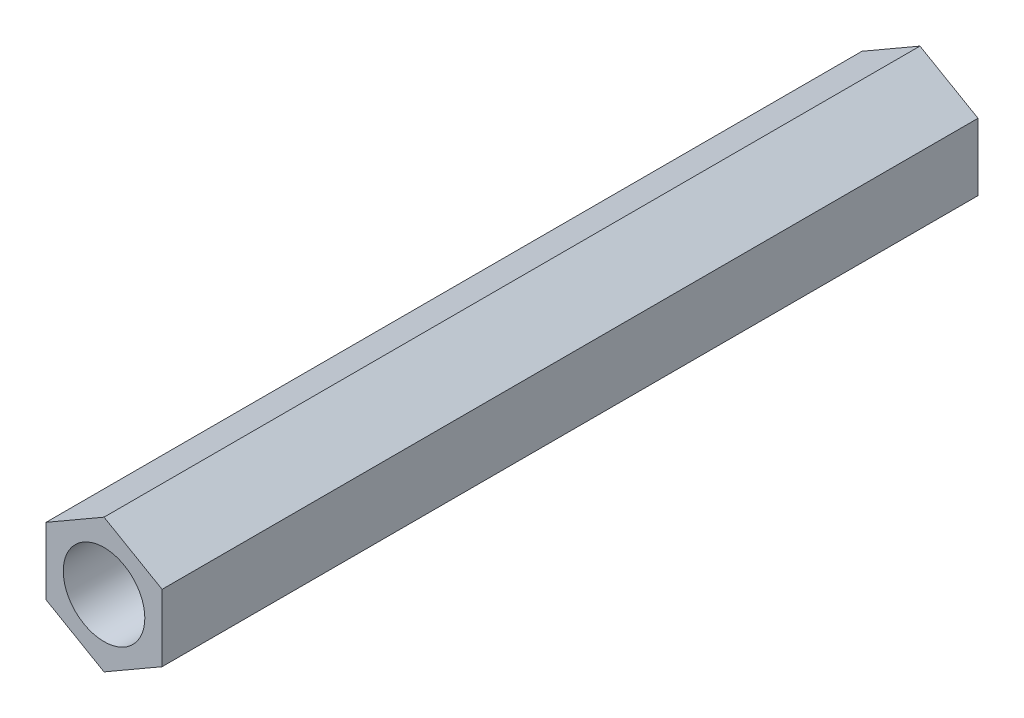
from build123d import *

# Parameters (mm, degrees)
SKETCH_1_R      = 1.5
EXTRUDE_1_DEPTH = 30


with BuildPart() as part:
    # 草图1 → 凸台-拉伸1 (new body)
    with BuildSketch(Plane.XY):
        Polygon((0, 2.463929225), (-2.133825302, 1.231964612), (-2.133825302, -1.231964612), (0, -2.463929225), (2.133825302, -1.231964612), (2.133825302, 1.231964612), align=None)
        Circle(SKETCH_1_R, mode=Mode.SUBTRACT)
    extrude(amount=EXTRUDE_1_DEPTH)


solid = part.part
